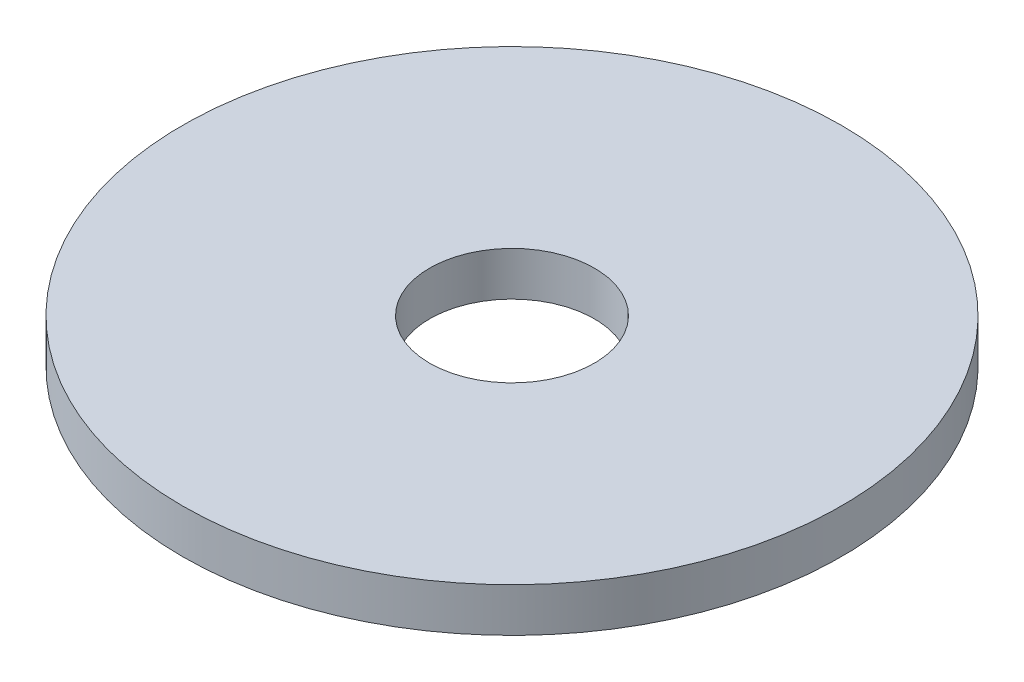
from build123d import *

# Parameters (mm, degrees)
SKETCH1_W = 5.625
SKETCH1_H = 1


with BuildPart() as part:
    # Sketch1 → Revolve1 (revolve)
    with BuildSketch(Plane.XY):
        with Locations((4.6875, 0.5)):
            Rectangle(SKETCH1_W, SKETCH1_H)
    revolve(axis=Axis((0, 2.340120938, 0), (0, -1, 0)))


solid = part.part
